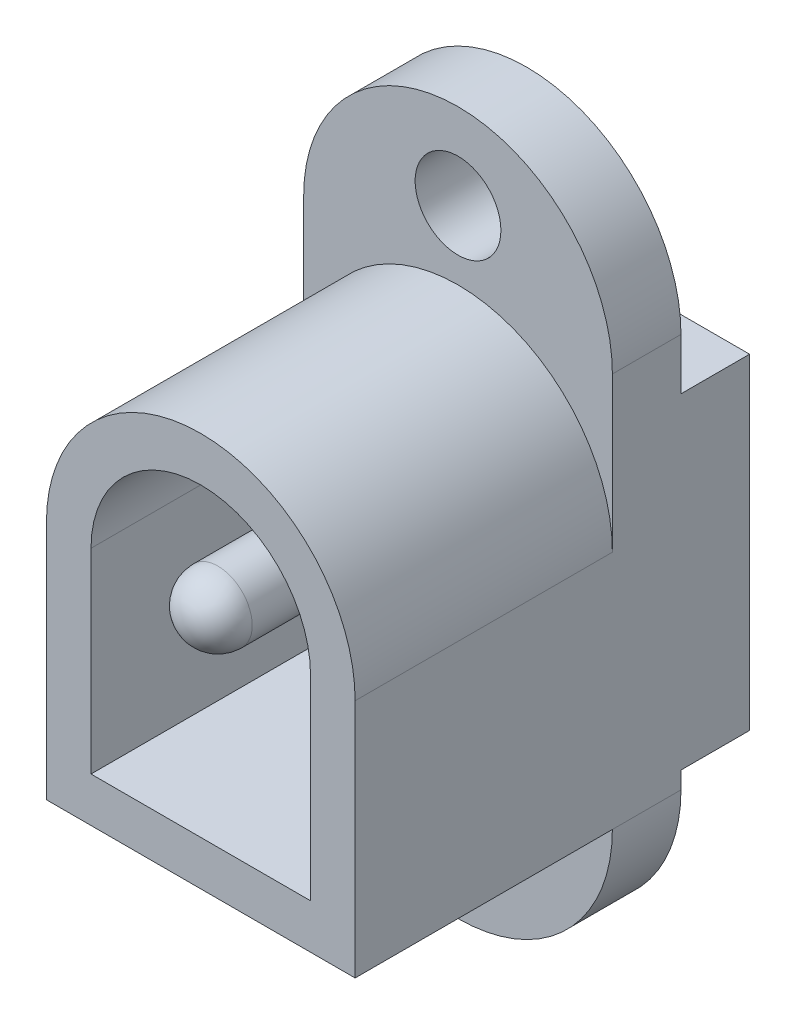
from build123d import *

# Parameters (mm, degrees)
SCHIZZO1_W                   = 9
SCHIZZO1_H                   = 11.5
ESTRUSIONE_ESTRUSIONE1_DEPTH = 2
SCHIZZO2_R                   = 4.5
ESTRUSIONE_ESTRUSIONE2_DEPTH = 2
SCHIZZO3_R                   = 1.25
TAGLIO_ESTRUSIONE1_DEPTH     = 2
ESTRUSIONE_ESTRUSIONE4_DEPTH = 7.5
TAGLIO_ESTRUSIONE2_DEPTH     = 7.5
SCHIZZO7_R                   = 1
ESTRUSIONE_ESTRUSIONE5_DEPTH = 8
RACCORDO1_R                  = 1
SCHIZZO8_W                   = 9
SCHIZZO8_H                   = 9.5
ESTRUSIONE_ESTRUSIONE6_DEPTH = 2


with BuildPart() as part:
    # Schizzo1 → Estrusione-Estrusione1 (new body)
    with BuildSketch(Plane.XY):
        Rectangle(SCHIZZO1_W, SCHIZZO1_H)
    extrude(amount=ESTRUSIONE_ESTRUSIONE1_DEPTH)

    # Schizzo2 → Estrusione-Estrusione2 (add)
    with BuildSketch(Plane.XY.offset(2)):
        with Locations((0, 5.75)):
            Circle(SCHIZZO2_R)
        with Locations((0, -5.75)):
            Circle(SCHIZZO2_R)
    extrude(amount=-ESTRUSIONE_ESTRUSIONE2_DEPTH)

    # Schizzo3 → Taglio-Estrusione1 (cut)
    with BuildSketch(Plane.XY.offset(2)):
        with Locations((0, -7.75)):
            Circle(SCHIZZO3_R)
        with Locations((0, 7.75)):
            Circle(SCHIZZO3_R)
    extrude(amount=-TAGLIO_ESTRUSIONE1_DEPTH, mode=Mode.SUBTRACT)

    # Schizzo4 → Estrusione-Estrusione4 (add)
    with BuildSketch(Plane.XY.offset(2)):
        with BuildLine():
            ThreePointArc((4.5, 1.25), (0, 5.75), (-4.5, 1.25))
            Line((-4.5, 1.25), (4.5, 1.25))
        make_face()
        with BuildLine():
            Line((4.5, 1.25), (-4.5, 1.25))
            ThreePointArc((-4.5, 1.25), (0, -3.25), (4.5, 1.25))
        make_face()
        with BuildLine():
            ThreePointArc((4.5, 1.25), (0, 5.75), (-4.5, 1.25))
            Line((-4.5, 1.25), (4.5, 1.25))
        make_face()
        with BuildLine():
            Line((4.5, 1.25), (-4.5, 1.25))
            ThreePointArc((-4.5, 1.25), (0, -3.25), (4.5, 1.25))
        make_face()
        with BuildLine():
            Line((-4.5, 1.25), (-4.5, -5.75))
            Line((-4.5, -5.75), (4.5, -5.75))
            Line((4.5, -5.75), (4.5, 1.25))
            ThreePointArc((4.5, 1.25), (0, -3.25), (-4.5, 1.25))
        make_face()
    extrude(amount=ESTRUSIONE_ESTRUSIONE4_DEPTH)

    # Schizzo6 → Taglio-Estrusione2 (cut)
    with BuildSketch(Plane.XY.offset(9.5)):
        with BuildLine():
            ThreePointArc((3.2, 1.25), (0, 4.45), (-3.2, 1.25))
            Line((-3.2, 1.25), (3.2, 1.25))
        make_face()
        with BuildLine():
            Line((3.2, 1.25), (-3.2, 1.25))
            ThreePointArc((-3.2, 1.25), (0, -1.95), (3.2, 1.25))
        make_face()
        with BuildLine():
            ThreePointArc((3.2, 1.25), (0, 4.45), (-3.2, 1.25))
            Line((-3.2, 1.25), (3.2, 1.25))
        make_face()
        with BuildLine():
            Line((3.2, 1.25), (-3.2, 1.25))
            ThreePointArc((-3.2, 1.25), (0, -1.95), (3.2, 1.25))
        make_face()
        with BuildLine():
            ThreePointArc((3.2, 1.25), (0, -1.95), (-3.2, 1.25))
            Line((-3.2, 1.25), (-3.2, -4.45))
            Line((-3.2, -4.45), (3.2, -4.45))
            Line((3.2, -4.45), (3.2, 1.25))
        make_face()
    extrude(amount=-TAGLIO_ESTRUSIONE2_DEPTH, mode=Mode.SUBTRACT)

    # Schizzo7 → Estrusione-Estrusione5 (add)
    with BuildSketch(Plane.XY.offset(2)):
        with Locations((0, 1.15)):
            Circle(SCHIZZO7_R)
    extrude(amount=ESTRUSIONE_ESTRUSIONE5_DEPTH)

    # Raccordo1
    raccordo1_edges = [part.edges().sort_by_distance(p)[0] for p in [
        (-1, 1.15, 10),
    ]]
    fillet(raccordo1_edges, radius=RACCORDO1_R)

    # Schizzo8 → Estrusione-Estrusione6 (add)
    with BuildSketch(Plane(origin=(0, 0, 0), x_dir=(-1, 0, 0), z_dir=(0, 0, -1))):
        with Locations((0, -0.5)):
            Rectangle(SCHIZZO8_W, SCHIZZO8_H)
    extrude(amount=ESTRUSIONE_ESTRUSIONE6_DEPTH)


solid = part.part
